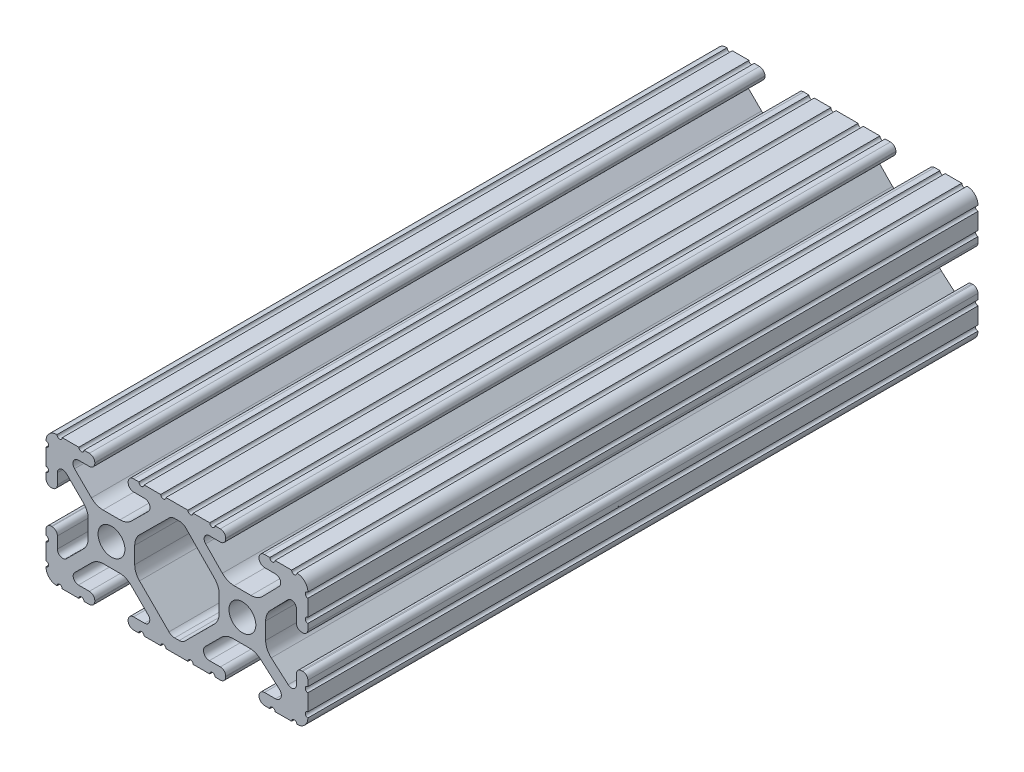
from build123d import *

# Parameters (mm, degrees)
SKETCH1_R      = 2.6035
EXTRUDE1_DEPTH = 130


with BuildPart() as part:
    # Sketch1 → Extrude1 (new body)
    with BuildSketch(Plane.XY):
        with BuildLine():
            Line((22.2504, 12.7), (19.03310265, 12.7))
            ThreePointArc((19.03310265, 12.7), (18.52510265, 12.192), (18.01710265, 12.7))
            Line((18.01710265, 12.7), (16.98745015, 12.7))
            ThreePointArc((16.98745015, 12.7), (16.245730386, 12.392769614), (15.9385, 11.65104985))
            Line((15.9385, 11.65104985), (15.9385, 11.53922))
            ThreePointArc((15.9385, 11.53922), (16.245750844, 10.797450844), (16.98752, 10.4902))
            Line((16.98752, 10.4902), (19.116384363, 10.4902))
            ThreePointArc((19.116384363, 10.4902), (20.052502933, 9.869096983), (19.844087081, 8.765172272))
            Line((19.844087081, 8.765172272), (16.618993479, 5.455112286))
            ThreePointArc((16.618993479, 5.455112286), (15.578994274, 4.745442459), (14.344932584, 4.4958))
            Line((14.344932584, 4.4958), (11.083317835, 4.4958))
            ThreePointArc((11.083317835, 4.4958), (9.854330953, 4.743306833), (8.816955189, 5.447238587))
            Line((8.816955189, 5.447238587), (5.564154119, 8.762652677))
            ThreePointArc((5.564154119, 8.762652677), (5.352591412, 9.867473037), (6.289393385, 10.4902))
            Line((6.289393385, 10.4902), (8.41248, 10.4902))
            ThreePointArc((8.41248, 10.4902), (9.154249156, 10.797450844), (9.4615, 11.53922))
            Line((9.4615, 11.53922), (9.4615, 11.65104985))
            ThreePointArc((9.4615, 11.65104985), (9.154269614, 12.392769614), (8.41254985, 12.7))
            Line((8.41254985, 12.7), (7.38288465, 12.7))
            ThreePointArc((7.38288465, 12.7), (6.87488465, 12.192), (6.36688465, 12.7))
            Line((6.36688465, 12.7), (3.14958095, 12.7))
            ThreePointArc((3.14958095, 12.7), (2.64158095, 12.192), (2.13358095, 12.7))
            Line((2.13358095, 12.7), (-2.13358095, 12.7))
            ThreePointArc((-2.13358095, 12.7), (-2.64158095, 12.192), (-3.14958095, 12.7))
            Line((-3.14958095, 12.7), (-6.36689735, 12.7))
            ThreePointArc((-6.36689735, 12.7), (-6.87489735, 12.192), (-7.38289735, 12.7))
            Line((-7.38289735, 12.7), (-8.41254985, 12.7))
            ThreePointArc((-8.41254985, 12.7), (-9.154269614, 12.392769614), (-9.4615, 11.65104985))
            Line((-9.4615, 11.65104985), (-9.4615, 11.53922))
            ThreePointArc((-9.4615, 11.53922), (-9.154249156, 10.797450844), (-8.41248, 10.4902))
            Line((-8.41248, 10.4902), (-6.283641037, 10.4902))
            ThreePointArc((-6.283641037, 10.4902), (-5.297291557, 9.829633109), (-5.532576693, 8.666071843))
            Line((-5.532576693, 8.666071843), (-8.809985098, 5.416263103))
            ThreePointArc((-8.809985098, 5.416263103), (-9.836720513, 4.734920264), (-11.045536121, 4.4958))
            Line((-11.045536121, 4.4958), (-14.354463879, 4.4958))
            ThreePointArc((-14.354463879, 4.4958), (-15.563279487, 4.734920264), (-16.590014902, 5.416263103))
            Line((-16.590014902, 5.416263103), (-19.867423307, 8.666071843))
            ThreePointArc((-19.867423307, 8.666071843), (-20.102708443, 9.829633109), (-19.116358963, 10.4902))
            Line((-19.116358963, 10.4902), (-16.98752, 10.4902))
            ThreePointArc((-16.98752, 10.4902), (-16.245750844, 10.797450844), (-15.9385, 11.53922))
            Line((-15.9385, 11.53922), (-15.9385, 11.65104985))
            ThreePointArc((-15.9385, 11.65104985), (-16.245730386, 12.392769614), (-16.98745015, 12.7))
            Line((-16.98745015, 12.7), (-18.01711535, 12.7))
            ThreePointArc((-18.01711535, 12.7), (-18.52511535, 12.192), (-19.03311535, 12.7))
            Line((-19.03311535, 12.7), (-22.2504, 12.7))
            ThreePointArc((-22.2504, 12.7), (-22.758323491, 12.192000006), (-23.266399977, 12.699846982))
            ThreePointArc((-23.266399977, 12.699846982), (-24.782522516, 12.082522516), (-25.399846982, 10.566399977))
            ThreePointArc((-25.399846982, 10.566399977), (-24.892000006, 10.058323491), (-25.4, 9.5504))
            Line((-25.4, 9.5504), (-25.4, 6.3330836))
            ThreePointArc((-25.4, 6.3330836), (-24.892, 5.8250836), (-25.4, 5.3170836))
            Line((-25.4, 5.3170836), (-25.4, 4.237520184))
            ThreePointArc((-25.4, 4.237520184), (-25.107393763, 3.531106237), (-24.400979816, 3.2385))
            Line((-24.400979816, 3.2385), (-24.23922, 3.2385))
            ThreePointArc((-24.23922, 3.2385), (-23.497450844, 3.545750844), (-23.1902, 4.28752))
            Line((-23.1902, 4.28752), (-23.1902, 6.334741132))
            ThreePointArc((-23.1902, 6.334741132), (-22.556026952, 7.286023527), (-21.434002553, 7.066535717))
            Line((-21.434002553, 7.066535717), (-18.147950853, 3.808156468))
            ThreePointArc((-18.147950853, 3.808156468), (-17.452759693, 2.774838327), (-17.208501877, 1.553619571))
            Line((-17.208501877, 1.553619571), (-17.208501877, -1.695179196))
            ThreePointArc((-17.208501877, -1.695179196), (-17.450738657, -2.911536421), (-18.140486065, -3.942289578))
            Line((-18.140486065, -3.942289578), (-21.431579576, -7.227386226))
            ThreePointArc((-21.431579576, -7.227386226), (-22.55444896, -7.449940594), (-23.1902, -6.498002195))
            Line((-23.1902, -6.498002195), (-23.1902, -4.28752))
            ThreePointArc((-23.1902, -4.28752), (-23.497450844, -3.545750844), (-24.23922, -3.2385))
            Line((-24.23922, -3.2385), (-24.35098, -3.2385))
            ThreePointArc((-24.35098, -3.2385), (-25.092749156, -3.545750844), (-25.4, -4.28752))
            Line((-25.4, -4.28752), (-25.4, -5.3171344))
            ThreePointArc((-25.4, -5.3171344), (-24.892, -5.8251344), (-25.4, -6.3331344))
            Line((-25.4, -6.3331344), (-25.4, -9.5504))
            ThreePointArc((-25.4, -9.5504), (-24.892000006, -10.058323491), (-25.399846982, -10.566399977))
            ThreePointArc((-25.399846982, -10.566399977), (-24.782522516, -12.082522516), (-23.266399977, -12.699846982))
            ThreePointArc((-23.266399977, -12.699846982), (-22.758323491, -12.192000006), (-22.2504, -12.7))
            Line((-22.2504, -12.7), (-19.03308995, -12.7))
            ThreePointArc((-19.03308995, -12.7), (-18.52508995, -12.192), (-18.01708995, -12.7))
            Line((-18.01708995, -12.7), (-16.9874692, -12.7))
            ThreePointArc((-16.9874692, -12.7), (-16.245700044, -12.392749156), (-15.9384492, -11.65098))
            Line((-15.9384492, -11.65098), (-15.9384492, -11.53922))
            ThreePointArc((-15.9384492, -11.53922), (-16.245700044, -10.797450844), (-16.9874692, -10.4902))
            Line((-16.9874692, -10.4902), (-19.116358963, -10.4902))
            ThreePointArc((-19.116358963, -10.4902), (-20.055197748, -9.862578342), (-19.834124023, -8.755124678))
            Line((-19.834124023, -8.755124678), (-16.49660751, -5.423689618))
            ThreePointArc((-16.49660751, -5.423689618), (-15.467274017, -4.736928798), (-14.253591699, -4.4958))
            Line((-14.253591699, -4.4958), (-11.146408301, -4.4958))
            ThreePointArc((-11.146408301, -4.4958), (-9.932725983, -4.736928798), (-8.90339249, -5.423689618))
            Line((-8.90339249, -5.423689618), (-5.565875977, -8.755124678))
            ThreePointArc((-5.565875977, -8.755124678), (-5.344802252, -9.862578342), (-6.283641037, -10.4902))
            Line((-6.283641037, -10.4902), (-8.4125308, -10.4902))
            ThreePointArc((-8.4125308, -10.4902), (-9.154299956, -10.797450844), (-9.4615508, -11.53922))
            Line((-9.4615508, -11.53922), (-9.4615508, -11.65098))
            ThreePointArc((-9.4615508, -11.65098), (-9.154299956, -12.392749156), (-8.4125308, -12.7))
            Line((-8.4125308, -12.7), (-7.38287195, -12.7))
            ThreePointArc((-7.38287195, -12.7), (-6.87487195, -12.192), (-6.36687195, -12.7))
            Line((-6.36687195, -12.7), (-3.14960635, -12.7))
            ThreePointArc((-3.14960635, -12.7), (-2.64160635, -12.192), (-2.13360635, -12.7))
            Line((-2.13360635, -12.7), (2.13360635, -12.7))
            ThreePointArc((2.13360635, -12.7), (2.64159365, -12.1920127), (3.14958095, -12.7))
            Line((3.14958095, -12.7), (6.36691005, -12.7))
            ThreePointArc((6.36691005, -12.7), (6.87491005, -12.192), (7.38291005, -12.7))
            Line((7.38291005, -12.7), (8.4125308, -12.7))
            ThreePointArc((8.4125308, -12.7), (9.154299956, -12.392749156), (9.4615508, -11.65098))
            Line((9.4615508, -11.65098), (9.4615508, -11.53922))
            ThreePointArc((9.4615508, -11.53922), (9.154299956, -10.797450844), (8.4125308, -10.4902))
            Line((8.4125308, -10.4902), (6.289393385, -10.4902))
            ThreePointArc((6.289393385, -10.4902), (5.231590322, -9.783049717), (5.480677245, -8.535265862))
            Line((5.480677245, -8.535265862), (8.597933595, -5.423689618))
            ThreePointArc((8.597933595, -5.423689618), (9.627267088, -4.736928798), (10.840949406, -4.4958))
            Line((10.840949406, -4.4958), (14.102564155, -4.4958))
            ThreePointArc((14.102564155, -4.4958), (15.215927525, -4.697410182), (16.187895372, -5.276636531))
            Line((16.187895372, -5.276636531), (19.868247549, -8.482246082))
            ThreePointArc((19.868247549, -8.482246082), (20.188435806, -9.746879864), (19.116384363, -10.4902))
            Line((19.116384363, -10.4902), (16.9874692, -10.4902))
            ThreePointArc((16.9874692, -10.4902), (16.245700044, -10.797450844), (15.9384492, -11.53922))
            Line((15.9384492, -11.53922), (15.9384492, -11.65098))
            ThreePointArc((15.9384492, -11.65098), (16.245700044, -12.392749156), (16.9874692, -12.7))
            Line((16.9874692, -12.7), (18.01710265, -12.7))
            ThreePointArc((18.01710265, -12.7), (18.52510265, -12.192), (19.03310265, -12.7))
            Line((19.03310265, -12.7), (22.2504, -12.7))
            ThreePointArc((22.2504, -12.7), (22.758323491, -12.192000006), (23.266399977, -12.699846982))
            ThreePointArc((23.266399977, -12.699846982), (24.782522516, -12.082522516), (25.399846982, -10.566399977))
            ThreePointArc((25.399846982, -10.566399977), (24.892000006, -10.058323492), (25.4, -9.550400001))
            Line((25.4, -9.550400001), (25.4, -6.333083592))
            ThreePointArc((25.4, -6.333083592), (24.892000001, -5.825083593), (25.4, -5.317083593))
            Line((25.4, -5.317083593), (25.4, -4.237520184))
            ThreePointArc((25.4, -4.237520184), (25.107393763, -3.531106237), (24.400979816, -3.2385))
            Line((24.400979816, -3.2385), (24.189220184, -3.2385))
            ThreePointArc((24.189220184, -3.2385), (23.482806237, -3.531106237), (23.1902, -4.237520184))
            Line((23.1902, -4.237520184), (23.1902, -6.155876159))
            ThreePointArc((23.1902, -6.155876159), (22.62232736, -7.038258539), (21.583974541, -6.886926384))
            Line((21.583974541, -6.886926384), (18.29817066, -4.024970844))
            ThreePointArc((18.29817066, -4.024970844), (17.493730985, -2.946044689), (17.208501877, -1.630807374))
            Line((17.208501877, -1.630807374), (17.208501877, 1.630807374))
            ThreePointArc((17.208501877, 1.630807374), (17.442348332, 2.82673414), (18.109440981, 3.846495088))
            Line((18.109440981, 3.846495088), (21.526346532, 7.353420386))
            ThreePointArc((21.526346532, 7.353420386), (22.585896263, 7.574939077), (23.1902, 6.676867167))
            Line((23.1902, 6.676867167), (23.1902, 4.237520184))
            ThreePointArc((23.1902, 4.237520184), (23.482806237, 3.531106237), (24.189220184, 3.2385))
            Line((24.189220184, 3.2385), (24.400979816, 3.2385))
            ThreePointArc((24.400979816, 3.2385), (25.107393763, 3.531106237), (25.4, 4.237520184))
            Line((25.4, 4.237520184), (25.4, 5.3170836))
            ThreePointArc((25.4, 5.3170836), (24.891949193, 5.825134407), (25.4, 6.333185215))
            Line((25.4, 6.333185215), (25.4, 9.550400015))
            ThreePointArc((25.4, 9.550400015), (24.892000013, 10.058323498), (25.399846982, 10.566399977))
            ThreePointArc((25.399846982, 10.566399977), (24.782522516, 12.082522516), (23.266399977, 12.699846982))
            ThreePointArc((23.266399977, 12.699846982), (22.758323491, 12.192000006), (22.2504, 12.7))
        make_face()
        with Locations((-12.7, 0)):
            Circle(SKETCH1_R, mode=Mode.SUBTRACT)
        with Locations((12.7, 0)):
            Circle(SKETCH1_R, mode=Mode.SUBTRACT)
        with BuildLine():
            Line((-7.259513935, -3.869413038), (-1.545748891, -9.572766749))
            ThreePointArc((-1.545748891, -9.572766749), (-1.035199478, -9.913400116), (-0.433213048, -10.033))
            Line((-0.433213048, -10.033), (0.433213048, -10.033))
            ThreePointArc((0.433213048, -10.033), (1.035199478, -9.913400116), (1.545748891, -9.572766749))
            Line((1.545748891, -9.572766749), (7.259513935, -3.869413038))
            ThreePointArc((7.259513935, -3.869413038), (7.949261343, -2.838659881), (8.191498123, -1.622302656))
            Line((8.191498123, -1.622302656), (8.191498123, 1.622302656))
            ThreePointArc((8.191498123, 1.622302656), (7.955573352, 2.823327967), (7.282860769, 3.845864069))
            Line((7.282860769, 3.845864069), (1.675572808, 9.561086461))
            ThreePointArc((1.675572808, 9.561086461), (1.161034429, 9.910236611), (0.551456936, 10.033))
            Line((0.551456936, 10.033), (-0.395199982, 10.033))
            ThreePointArc((-0.395199982, 10.033), (-0.994772524, 9.914396349), (-1.50403329, 9.576450301))
            Line((-1.50403329, 9.576450301), (-7.252049147, 3.876839553))
            ThreePointArc((-7.252049147, 3.876839553), (-7.947240307, 2.843521412), (-8.191498123, 1.622302656))
            Line((-8.191498123, 1.622302656), (-8.191498123, -1.622302656))
            ThreePointArc((-8.191498123, -1.622302656), (-7.949261343, -2.838659881), (-7.259513935, -3.869413038))
        make_face(mode=Mode.SUBTRACT)
    extrude(amount=-EXTRUDE1_DEPTH)


solid = part.part
